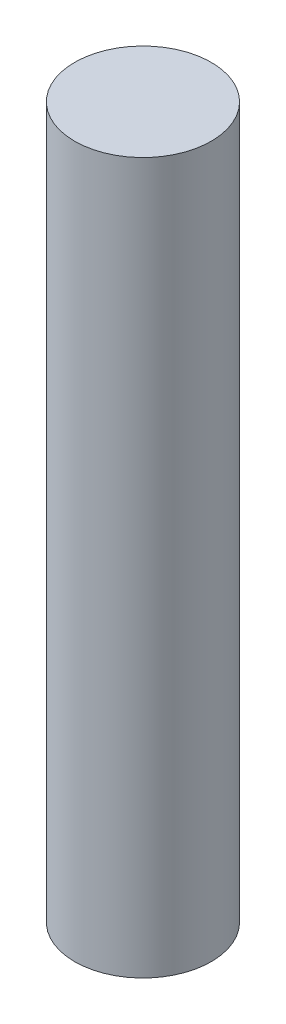
from build123d import *

# Parameters (mm, degrees)
SKETCH1_R           = 1.25
BOSS_EXTRUDE1_DEPTH = 13


with BuildPart() as part:
    # Sketch1 → Boss-Extrude1 (new body)
    with BuildSketch(Plane(origin=(0, 0, 0), x_dir=(1, 0, 0), z_dir=(0, 1, 0))):
        Circle(SKETCH1_R)
    extrude(amount=BOSS_EXTRUDE1_DEPTH)


solid = part.part
